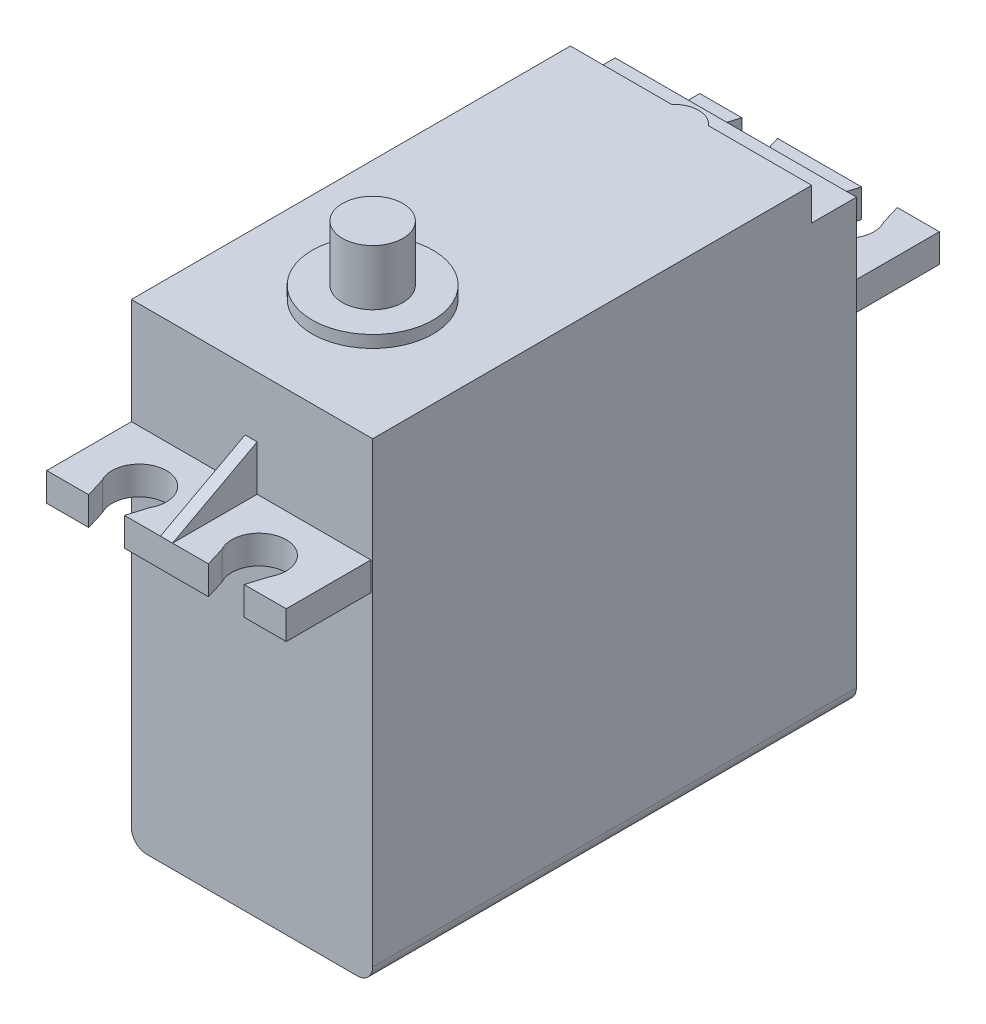
from build123d import *

# Parameters (mm, degrees)
BOSS_EXTRUDE1_DEPTH = 40
BOSS_EXTRUDE3_DEPTH = 2.35
BOSS_EXTRUDE4_DEPTH = 2.7
SKETCH7_R           = 5
BOSS_EXTRUDE5_DEPTH = 1
SKETCH8_R           = 2.5
BOSS_EXTRUDE6_DEPTH = 4.6
BOSS_EXTRUDE7_DEPTH = 0.5


with BuildPart() as part:
    # Sketch1 → Boss-Extrude1 (new body)
    with BuildSketch(Plane.XY):
        with BuildLine():
            Line((1.27, 0), (18.68, 0))
            ThreePointArc((18.68, 0), (19.578025612, 0.371974388), (19.95, 1.27))
            Line((19.95, 1.27), (19.95, 36.4))
            Line((19.95, 36.4), (0, 36.4))
            Line((0, 36.4), (0, 1.27))
            ThreePointArc((0, 1.27), (0.371974388, 0.371974388), (1.27, 0))
        make_face()
    extrude(amount=BOSS_EXTRUDE1_DEPTH)

    # Sketch5 → Boss-Extrude3 (add)
    with BuildSketch(Plane(origin=(0, 28, 0), x_dir=(-1, 0, 0), z_dir=(0, -1, 0))):
        with BuildLine():
            Line((0, 0), (0, 7))
            Line((0, 7), (-3.470401751, 7))
            Line((-3.470401751, 7), (-2.98203275, 5.390690104))
            ThreePointArc((-2.98203275, 5.390690104), (-4.95, 2.05), (-6.91796725, 5.390690104))
            Line((-6.91796725, 5.390690104), (-6.429598249, 7))
            Line((-6.429598249, 7), (-13.370401751, 7))
            Line((-13.370401751, 7), (-12.88203275, 5.390690104))
            ThreePointArc((-12.88203275, 5.390690104), (-14.85, 2.05), (-16.81796725, 5.390690104))
            Line((-16.81796725, 5.390690104), (-16.329598249, 7))
            Line((-16.329598249, 7), (-19.8, 7))
            Line((-19.8, 7), (-19.8, 0))
            Line((-19.8, 0), (0, 0))
        make_face()
        with BuildLine():
            Line((-16.329598249, -47), (-16.81796725, -45.390690104))
            ThreePointArc((-16.81796725, -45.390690104), (-14.85, -42.05), (-12.88203275, -45.390690104))
            Line((-12.88203275, -45.390690104), (-13.370401751, -47))
            Line((-13.370401751, -47), (-6.429598249, -47))
            Line((-6.429598249, -47), (-6.91796725, -45.390690104))
            ThreePointArc((-6.91796725, -45.390690104), (-4.95, -42.05), (-2.98203275, -45.390690104))
            Line((-2.98203275, -45.390690104), (-3.470401751, -47))
            Line((-3.470401751, -47), (0, -47))
            Line((0, -47), (0, -40))
            Line((0, -40), (-19.8, -40))
            Line((-19.8, -40), (-19.8, -47))
            Line((-19.8, -47), (-16.329598249, -47))
        make_face()
    extrude(amount=-BOSS_EXTRUDE3_DEPTH)

    # Sketch6 → Boss-Extrude4 (add)
    with BuildSketch(Plane(origin=(0, 36.4, 0), x_dir=(1, 0, 0), z_dir=(0, 1, 0))):
        with BuildLine():
            Line((19.95, -3.7), (19.95, -40))
            Line((19.95, -40), (0, -40))
            Line((0, -40), (0, -3.7))
            Line((0, -3.7), (8.380131585, -3.7))
            ThreePointArc((8.380131585, -3.7), (9.9, -3), (11.419868415, -3.7))
            Line((11.419868415, -3.7), (19.95, -3.7))
        make_face()
    extrude(amount=BOSS_EXTRUDE4_DEPTH)

    # Sketch7 → Boss-Extrude5 (add)
    with BuildSketch(Plane(origin=(0, 39.1, 0), x_dir=(1, 0, 0), z_dir=(0, 1, 0))):
        with Locations((9.95, -30)):
            Circle(SKETCH7_R)
    extrude(amount=BOSS_EXTRUDE5_DEPTH)

    # Sketch8 → Boss-Extrude6 (add)
    with BuildSketch(Plane(origin=(0, 40.1, 0), x_dir=(1, 0, 0), z_dir=(0, 1, 0))):
        with Locations((9.95, -30)):
            Circle(SKETCH8_R)
    extrude(amount=BOSS_EXTRUDE6_DEPTH)

    # Sketch9 → Boss-Extrude7 (add, symmetric)
    with BuildSketch(Plane.ZY.offset(-9.9)):
        Polygon((47, 30.35), (40, 34.1), (40, 30.35), align=None)
    extrude(amount=BOSS_EXTRUDE7_DEPTH, both=True)


solid = part.part
